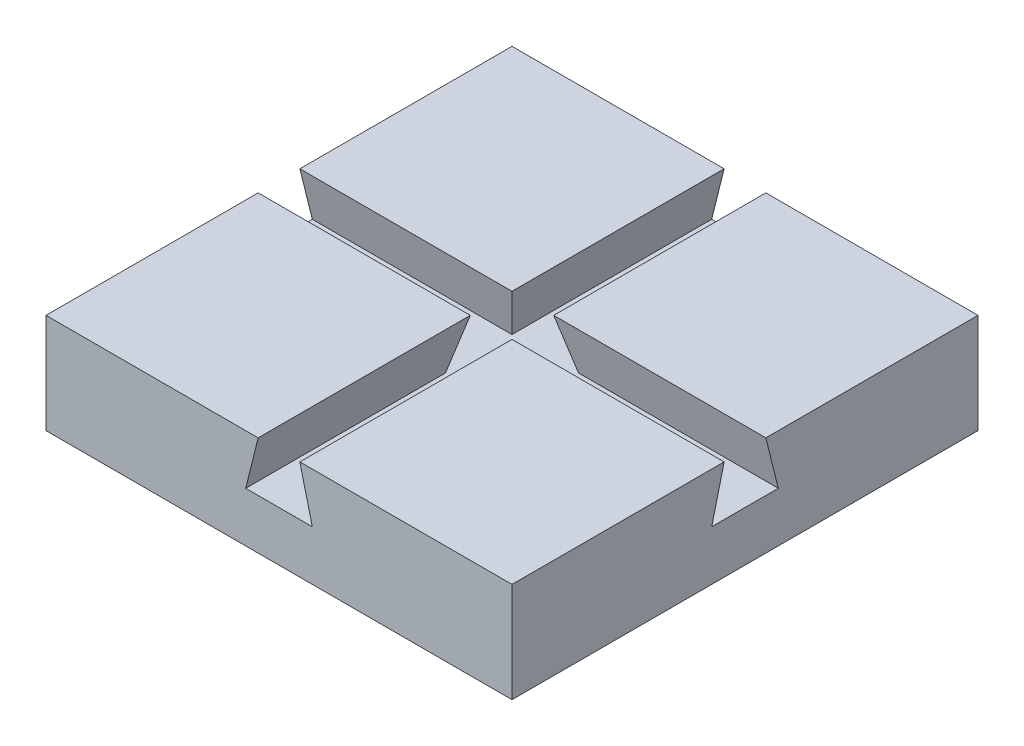
from build123d import *

# Parameters (mm, degrees)
SKETCH1_W          = 88.9
SKETCH1_H          = 88.9
BASE_EXTRUDE_DEPTH = 19.05
CUT_EXTRUDE1_DEPTH = 89.9
CUT_EXTRUDE2_DEPTH = 89.9


with BuildPart() as part:
    # Sketch1 → Base-Extrude (new body)
    with BuildSketch(Plane(origin=(0, 0, 0), x_dir=(1, 0, 0), z_dir=(0, 1, 0))):
        Rectangle(SKETCH1_W, SKETCH1_H)
    extrude(amount=BASE_EXTRUDE_DEPTH)

    # Sketch2 → Cut-Extrude1 (cut, through all)
    with BuildSketch(Plane.XY.offset(44.45)):
        Polygon((6.35, 9.525), (-6.35, 9.525), (-3.975150773, 19.05), (3.975150773, 19.05), align=None)
    extrude(amount=-CUT_EXTRUDE1_DEPTH, mode=Mode.SUBTRACT)

    # Sketch3 → Cut-Extrude2 (cut, through all)
    with BuildSketch(Plane(origin=(44.45, -3.538159269, -0.664564519), x_dir=(0, 0, -1), z_dir=(1, 0, 0))):
        Polygon((5.685435481, 13.063159269), (-7.014564519, 13.063159269), (-4.639715292, 22.588159269), (3.310586254, 22.588159269), align=None)
    extrude(amount=-CUT_EXTRUDE2_DEPTH, mode=Mode.SUBTRACT)


solid = part.part
